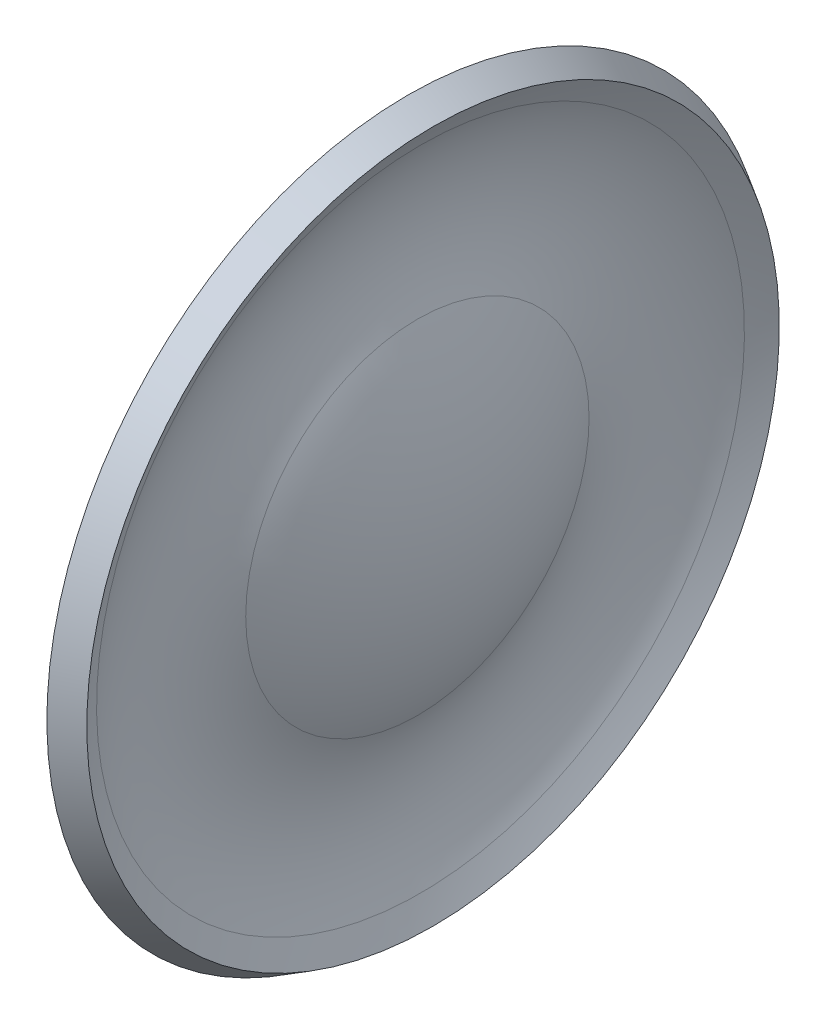
from build123d import *


with BuildPart() as part:
    # Sketch2 → Revolve3 (revolve)
    with BuildSketch(Plane.XY):
        with BuildLine():
            Line((-6.207251716, 0), (-5.902451716, 0))
            ThreePointArc((-5.902451716, 0), (-6.007248355, 0.920400933), (-6.316273469, 1.793684216))
            ThreePointArc((-6.316273469, 1.793684216), (-6.492146073, 2.592870349), (-6.284040137, 3.384275155))
            ThreePointArc((-6.284040137, 3.384275155), (-6.219504795, 3.50146239), (-6.15278435, 3.617419454))
            Line((-6.15278435, 3.617419454), (-6.415536706, 3.7719))
            ThreePointArc((-6.415536706, 3.7719), (-6.485106423, 3.650991033), (-6.552397723, 3.52879936))
            ThreePointArc((-6.552397723, 3.52879936), (-6.796883506, 2.599045854), (-6.590265895, 1.660150735))
            ThreePointArc((-6.590265895, 1.660150735), (-6.304246614, 0.851880321), (-6.207251716, 0))
        make_face()
    revolve(axis=Axis((0, 0, 0), (-1, 0, 0)))


solid = part.part
